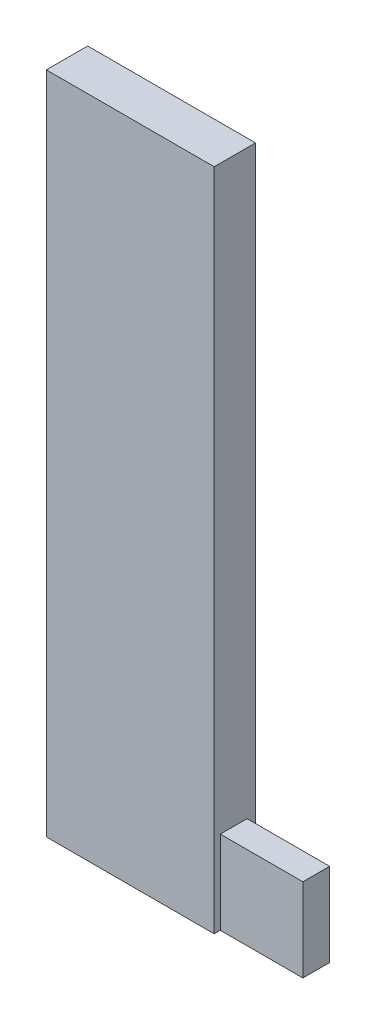
from build123d import *

# Parameters (mm, degrees)
SKETCH1_W           = 5.162383308
SKETCH1_H           = 20.435052184
BOSS_EXTRUDE1_DEPTH = 1.27
SKETCH2_W           = 0.838933851
SKETCH2_H           = 3.882140463
CUT_EXTRUDE1_DEPTH  = 3.81
SKETCH3_W           = 0.823014711
SKETCH3_H           = 2.56348928
BOSS_EXTRUDE2_DEPTH = 2.54


with BuildPart() as part:
    # Sketch1 → Boss-Extrude1 (new body)
    with BuildSketch(Plane.XY):
        with Locations((-34.98361032, 7.835499756)):
            Rectangle(SKETCH1_W, SKETCH1_H)
    extrude(amount=BOSS_EXTRUDE1_DEPTH)

    # Sketch2 → Cut-Extrude1 (cut)
    with BuildSketch(Plane.ZY.offset(37.564801974)):
        with Locations((0.611191145, 14.932897959)):
            Rectangle(SKETCH2_W, SKETCH2_H)
    extrude(amount=-CUT_EXTRUDE1_DEPTH, mode=Mode.SUBTRACT)

    # Sketch3 → Boss-Extrude2 (add)
    with BuildSketch(Plane(origin=(-32.402418666, 0, 0), x_dir=(0, 0, -1), z_dir=(1, 0, 0))):
        with Locations((-0.670761293, -1.100281696)):
            Rectangle(SKETCH3_W, SKETCH3_H)
    extrude(amount=BOSS_EXTRUDE2_DEPTH)


solid = part.part
